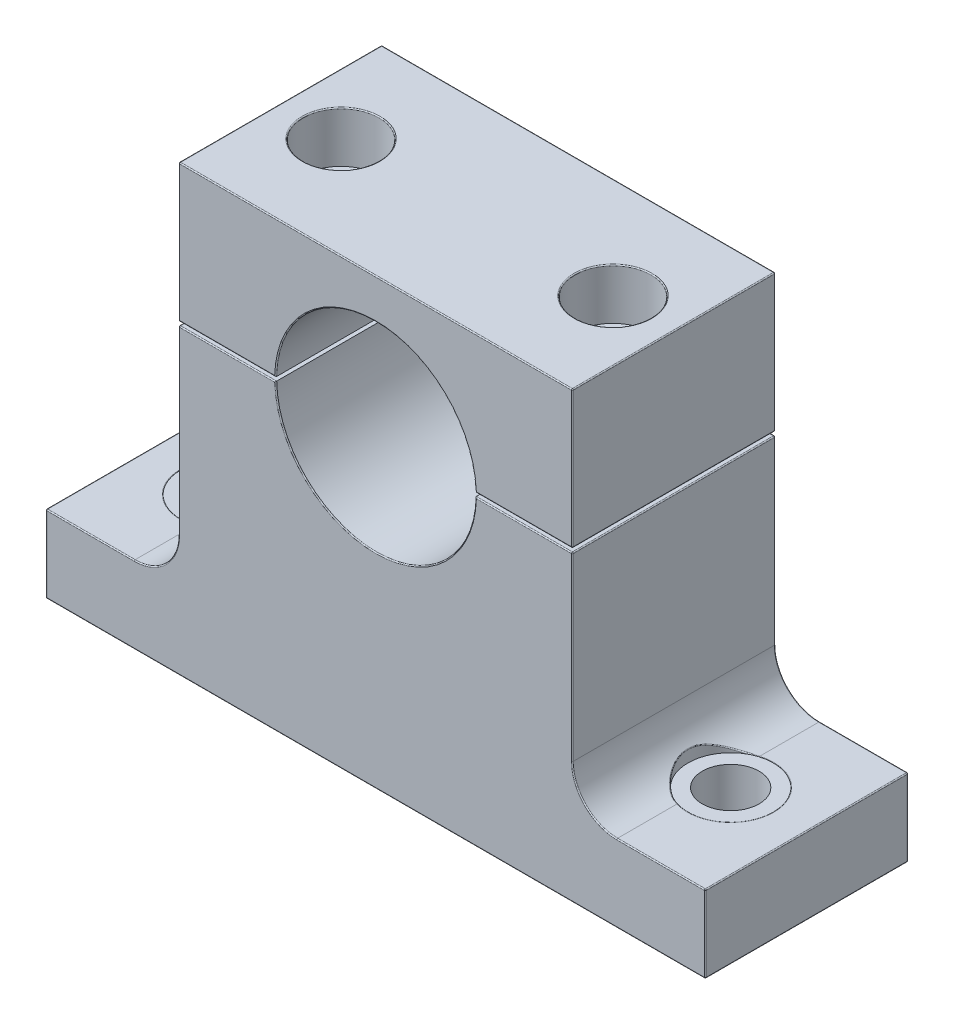
from build123d import *

# Parameters (mm, degrees)
BOSS_EXTRUDE1_DEPTH     = 12.7
BOSS_EXTRUDE1_2_DEPTH   = 12.7
SKETCH4_R               = 3.556
CUT_EXTRUDE1_DEPTH      = 64.029276017
SKETCH5_R               = 5.334
CUT_EXTRUDE2_DEPTH      = 64.029276017
CUT_EXTRUDE2_DEPTH_BACK = 0.02
SKETCH6_R               = 4.7625
CUT_EXTRUDE3_DEPTH      = 6.35
SKETCH8_R               = 3.175
CUT_EXTRUDE4_DEPTH      = 66.473550261
FILLET1_R               = 0.127
FILLET2_R               = 0.127


with BuildPart() as part:
    # Sketch2 → Boss-Extrude1 (new, symmetric)
    with BuildSketch(Plane.XY):
        with BuildLine():
            Line((-24.638, 17.4625), (24.638, 17.4625))
            Line((24.638, 17.4625), (24.638, 0.25))
            Line((24.638, 0.25), (12.49749975, 0.25))
            ThreePointArc((12.49749975, 0.25), (0, 12.5), (-12.49749975, 0.25))
            Line((-12.49749975, 0.25), (-24.638, 0.25))
            Line((-24.638, 0.25), (-24.638, 17.4625))
        make_face()
    extrude(amount=BOSS_EXTRUDE1_DEPTH, both=True)

    # Sketch6 → Cut-Extrude3 (cut)
    with BuildSketch(Plane(origin=(0, 17.4625, 0), x_dir=(1, 0, 0), z_dir=(0, 1, 0))):
        with Locations(Location((17.018, 0, 0), (0, 0, 180))):
            Circle(SKETCH6_R)
        with Locations(Location((-17.018, 0, 0), (0, 0, 180))):
            Circle(SKETCH6_R)
    extrude(amount=-CUT_EXTRUDE3_DEPTH, mode=Mode.SUBTRACT)


with BuildPart() as body_2:
    # Sketch2 → Boss-Extrude1 2 (new, symmetric)
    with BuildSketch(Plane.XY):
        with BuildLine():
            Line((41.275, -38.1), (-41.275, -38.1))
            Line((-41.275, -38.1), (-41.275, -28.448))
            Line((-41.275, -28.448), (-30.19425, -28.448))
            ThreePointArc((-30.19425, -28.448), (-26.265387947, -26.820612053), (-24.638, -22.89175))
            Line((-24.638, -22.89175), (-24.638, -0.25))
            Line((-24.638, -0.25), (-12.49749975, -0.25))
            ThreePointArc((-12.49749975, -0.25), (0, -12.5), (12.49749975, -0.25))
            Line((12.49749975, -0.25), (24.638, -0.25))
            Line((24.638, -0.25), (24.638, -22.89175))
            ThreePointArc((24.638, -22.89175), (26.265387947, -26.820612053), (30.19425, -28.448))
            Line((30.19425, -28.448), (41.275, -28.448))
            Line((41.275, -28.448), (41.275, -38.1))
        make_face()
    extrude(amount=BOSS_EXTRUDE1_2_DEPTH, both=True)

    # Sketch4 → Cut-Extrude1 (cut, through all)
    with BuildSketch(Plane(origin=(0, -28.448, 0), x_dir=(1, 0, 0), z_dir=(0, 1, 0))):
        with Locations(Location((-31.75, 0, 0), (0, 0, 180))):
            Circle(SKETCH4_R)
        with Locations(Location((31.75, 0, 0), (0, 0, 180))):
            Circle(SKETCH4_R)
    extrude(amount=-CUT_EXTRUDE1_DEPTH, mode=Mode.SUBTRACT)

    # Sketch5 → Cut-Extrude2 (cut, two sides)
    with BuildSketch(Plane(origin=(0, -28.448, 0), x_dir=(1, 0, 0), z_dir=(0, 1, 0))) as cut_extrude2_sk:
        with Locations(Location((31.75, 0, 0), (0, 0, 253.0422367))):
            Circle(SKETCH5_R)
        with Locations(Location((-31.75, 0, 0), (0, 0, 286.9577633))):
            Circle(SKETCH5_R)
    extrude(amount=CUT_EXTRUDE2_DEPTH, mode=Mode.SUBTRACT)
    extrude(cut_extrude2_sk.sketch, amount=-CUT_EXTRUDE2_DEPTH_BACK, mode=Mode.SUBTRACT)


with BuildPart() as cut_extrude4_tool:
    # Sketch8 → Cut-Extrude4 (new, through all)
    with BuildSketch(Plane(origin=(0, 11.1125, 0), x_dir=(1, 0, 0), z_dir=(0, 1, 0))):
        with Locations(Location((17.018, 0, 0), (0, 0, 180))):
            Circle(SKETCH8_R)
        with Locations(Location((-17.018, 0, 0), (0, 0, 180))):
            Circle(SKETCH8_R)
    extrude(amount=-CUT_EXTRUDE4_DEPTH)


with BuildPart() as part_1:
    add(part.part)

    # Cut-Extrude4: cut by cut_extrude4_tool
    add(cut_extrude4_tool.part, mode=Mode.SUBTRACT)

    # Fillet2
    fillet2_edges = [part_1.edges().sort_by_distance(p)[0] for p in [
        (0, 12.5, 12.7),
        (-24.638, 17.4625, 0),
        (24.638, 17.4625, 0),
        (24.638, 0.25, 0),
        (-24.638, 0.25, 0),
        (18.567749875, 0.25, 12.7),
        (24.638, 8.85625, 12.7),
        (0, 17.4625, 12.7),
        (21.7805, 17.4625, 0),
        (-12.2555, 17.4625, 0),
        (-24.638, 8.85625, 12.7),
        (0, 17.4625, -12.7),
        (24.638, 8.85625, -12.7),
        (18.567749875, 0.25, -12.7),
        (-18.567749875, 0.25, 12.7),
        (0, 12.5, -12.7),
        (-18.567749875, 0.25, -12.7),
        (-24.638, 8.85625, -12.7),
    ]]
    fillet(fillet2_edges, radius=FILLET2_R)


with BuildPart() as body_2_1:
    add(body_2.part)

    # Cut-Extrude4: cut by cut_extrude4_tool
    add(cut_extrude4_tool.part, mode=Mode.SUBTRACT)

    # Fillet1
    fillet1_edges = [body_2_1.edges().sort_by_distance(p)[0] for p in [
        (26.416, -26.965659793, 0),
        (-26.416, -26.965659793, 0),
        (35.306, -38.1, 0),
        (-28.194, -38.1, 0),
        (-13.843, -38.1, 0),
        (20.193, -38.1, 0),
        (41.275, -38.1, 0),
        (41.275, -28.448, 0),
        (24.638, -0.25, 0),
        (-24.638, -0.25, 0),
        (-41.275, -28.448, 0),
        (-41.275, -38.1, 0),
        (35.734625, -28.448, -12.7),
        (26.265387947, -26.820612053, -12.7),
        (24.638, -11.570875, -12.7),
        (18.567749875, -0.25, -12.7),
        (0, -12.5, -12.7),
        (-18.567749875, -0.25, -12.7),
        (-24.638, -11.570875, -12.7),
        (-26.265387947, -26.820612053, -12.7),
        (-35.734625, -28.448, -12.7),
        (-41.275, -33.274, -12.7),
        (0, -38.1, -12.7),
        (41.275, -33.274, -12.7),
        (0, -38.1, 12.7),
        (-41.275, -33.274, 12.7),
        (-35.734625, -28.448, 12.7),
        (-26.265387947, -26.820612053, 12.7),
        (-24.638, -11.570875, 12.7),
        (-18.567749875, -0.25, 12.7),
        (0, -12.5, 12.7),
        (18.567749875, -0.25, 12.7),
        (24.638, -11.570875, 12.7),
        (26.265387947, -26.820612053, 12.7),
        (35.734625, -28.448, 12.7),
        (41.275, -33.274, 12.7),
    ]]
    fillet(fillet1_edges, radius=FILLET1_R)


solid = Compound([part_1.part, body_2_1.part])
